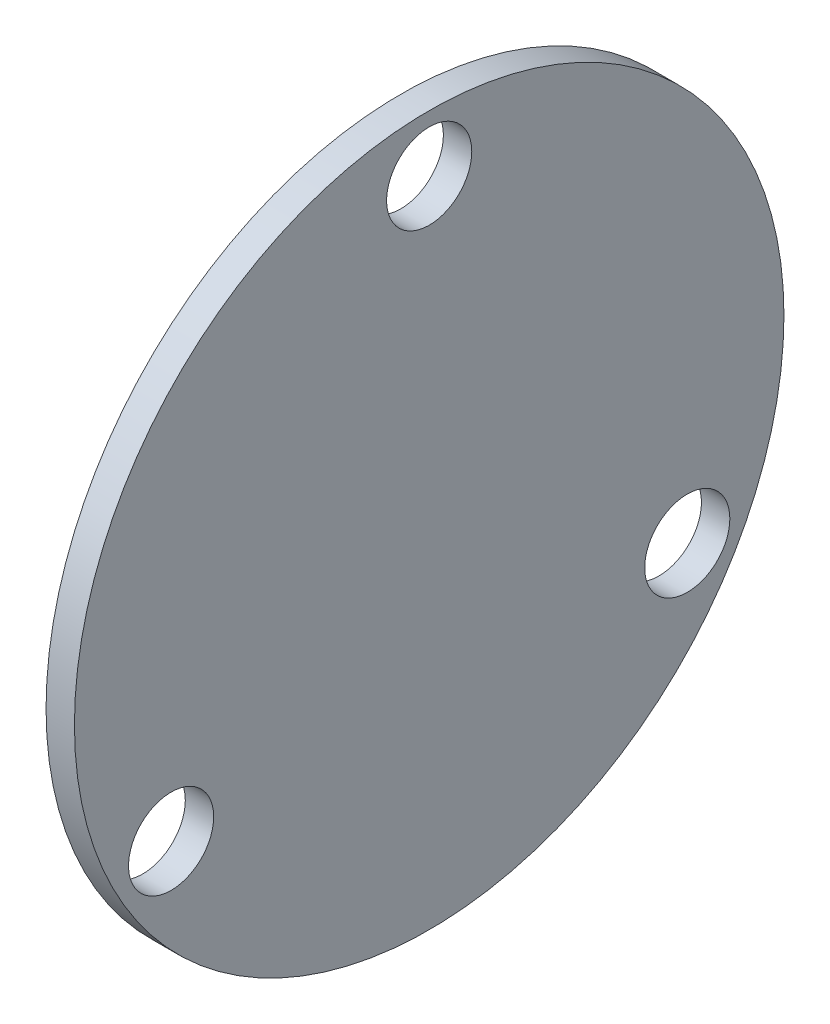
from build123d import *

# Parameters (mm, degrees)
ESQUISSE1_R             = 12.5
BOSS_EXTRU_1_DEPTH      = 1
ESQUISSE2_R             = 1.5
ENL_V_MAT_EXTRU_1_DEPTH = 1


with BuildPart() as part:
    # Esquisse1 → Boss.-Extru.1 (new body)
    with BuildSketch(Plane(origin=(0, 0, 0), x_dir=(0, 0, -1), z_dir=(1, 0, 0))):
        Circle(ESQUISSE1_R)
    extrude(amount=BOSS_EXTRU_1_DEPTH)

    # Esquisse2 → Enlèv. mat.-Extru.1 (cut)
    with BuildSketch(Plane(origin=(1, 0, 0), x_dir=(0, 0, -1), z_dir=(1, 0, 0))):
        with Locations((0, 10.5)):
            Circle(ESQUISSE2_R)
        with Locations((9.09326674, -5.25)):
            Circle(ESQUISSE2_R)
        with Locations((-9.09326674, -5.25)):
            Circle(ESQUISSE2_R)
    extrude(amount=-ENL_V_MAT_EXTRU_1_DEPTH, mode=Mode.SUBTRACT)


solid = part.part
